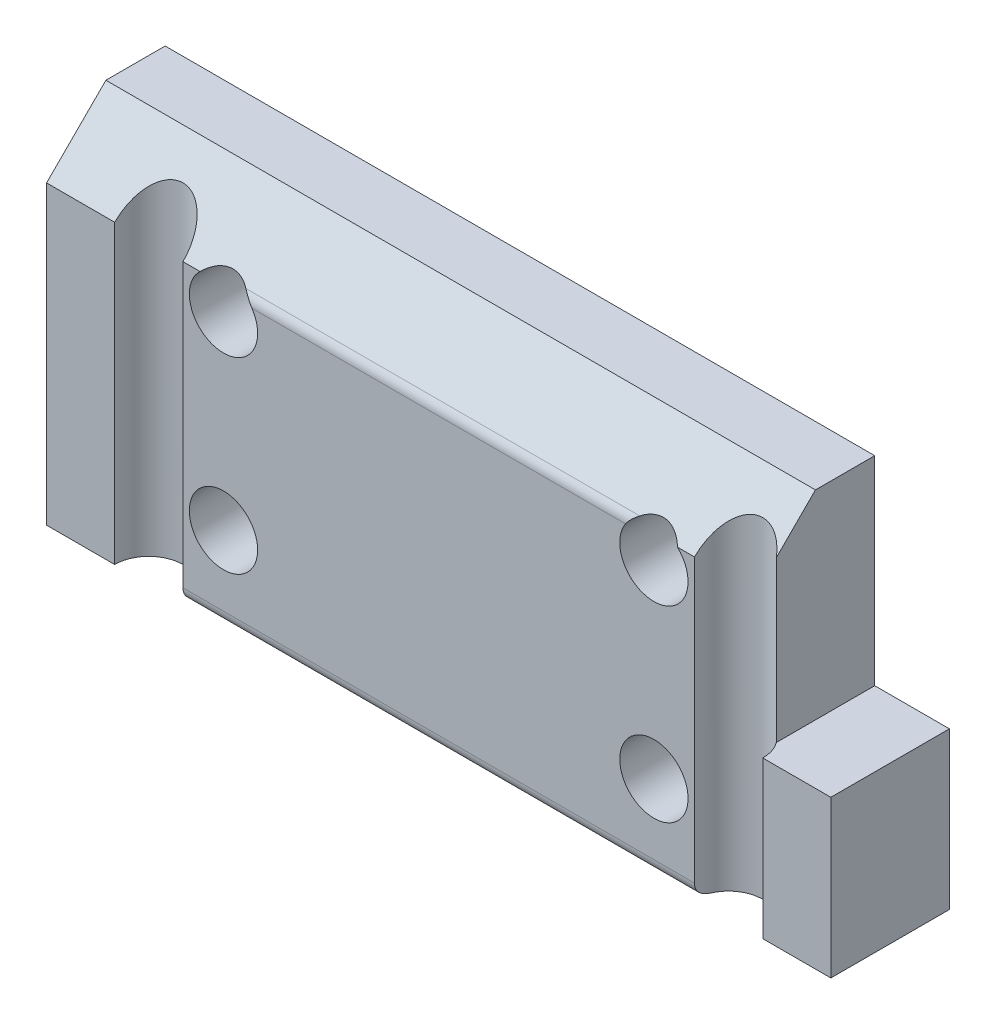
from build123d import *

# Parameters (mm, degrees)
BOSS_EXTRUDE1_DEPTH                            = 21
CBORE_FOR_6_SOCKET_HEAD_CAP_SCREW1_D           = 3.6576
CBORE_FOR_6_SOCKET_HEAD_CAP_SCREW1_DEPTH       = 9.398
CBORE_FOR_6_SOCKET_HEAD_CAP_SCREW1_CBORE_D     = 7.14502
CBORE_FOR_6_SOCKET_HEAD_CAP_SCREW1_CBORE_DEPTH = 2.54
CBORE_FOR_6_SOCKET_HEAD_CAP_SCREW1_TIP         = 1.0988539
F_6_CLEARANCE_HOLE1_D                          = 3.6576
FILLET1_R                                      = 0.75
SKETCH8_W                                      = 4
SKETCH8_H                                      = 10.668
CUT_EXTRUDE1_DEPTH                             = 24.917527635


with BuildPart() as part:
    # Sketch1 → Boss-Extrude1 (new, symmetric)
    with BuildSketch(Plane(origin=(0, 0, 0), x_dir=(0, 0, -1), z_dir=(1, 0, 0))):
        Polygon((0, 6.35), (3.175, 9.525), (6.35, 9.525), (6.35, -9.525), (0, -9.525), align=None)
    extrude(amount=BOSS_EXTRUDE1_DEPTH, both=True)

    # CBORE for _6 Socket Head Cap Screw1
    with Locations(Plane(origin=(0, 0, -6.35), x_dir=(-1, 0, 0), z_dir=(0, 0, -1))):
        with Locations((11.525, -5.025), (-11.525, 5.025), (-11.525, -5.025), (11.525, 5.025)):
            CounterBoreHole(CBORE_FOR_6_SOCKET_HEAD_CAP_SCREW1_D / 2, CBORE_FOR_6_SOCKET_HEAD_CAP_SCREW1_CBORE_D / 2, CBORE_FOR_6_SOCKET_HEAD_CAP_SCREW1_CBORE_DEPTH, depth=CBORE_FOR_6_SOCKET_HEAD_CAP_SCREW1_DEPTH)
            with Locations((0, 0, -(CBORE_FOR_6_SOCKET_HEAD_CAP_SCREW1_DEPTH + CBORE_FOR_6_SOCKET_HEAD_CAP_SCREW1_TIP / 2))):  # 118° drill point
                Cone(0, CBORE_FOR_6_SOCKET_HEAD_CAP_SCREW1_D / 2, CBORE_FOR_6_SOCKET_HEAD_CAP_SCREW1_TIP, mode=Mode.SUBTRACT)

    # 6 Clearance Hole1 (through all)
    with Locations(Plane(origin=(0, -9.525, 0), x_dir=(-1, 0, 0), z_dir=(0, -1, 0))):
        with Locations((-15.525, 0), (15.525, 0)):
            Hole(F_6_CLEARANCE_HOLE1_D / 2)

    # Fillet1
    fillet1_edges = [part.edges().sort_by_distance(p)[0] for p in [
        (0, 6.35, 0),
        (0, -9.525, 0),
    ]]
    fillet(fillet1_edges, radius=FILLET1_R)

    # Sketch8 → Cut-Extrude1 (cut, through all)
    with BuildSketch(Plane(origin=(0, 0, -6.35), x_dir=(-1, 0, 0), z_dir=(0, 0, -1))):
        with Locations((-19, 4.191)):
            Rectangle(SKETCH8_W, SKETCH8_H)
    extrude(amount=-CUT_EXTRUDE1_DEPTH, mode=Mode.SUBTRACT)


solid = part.part
